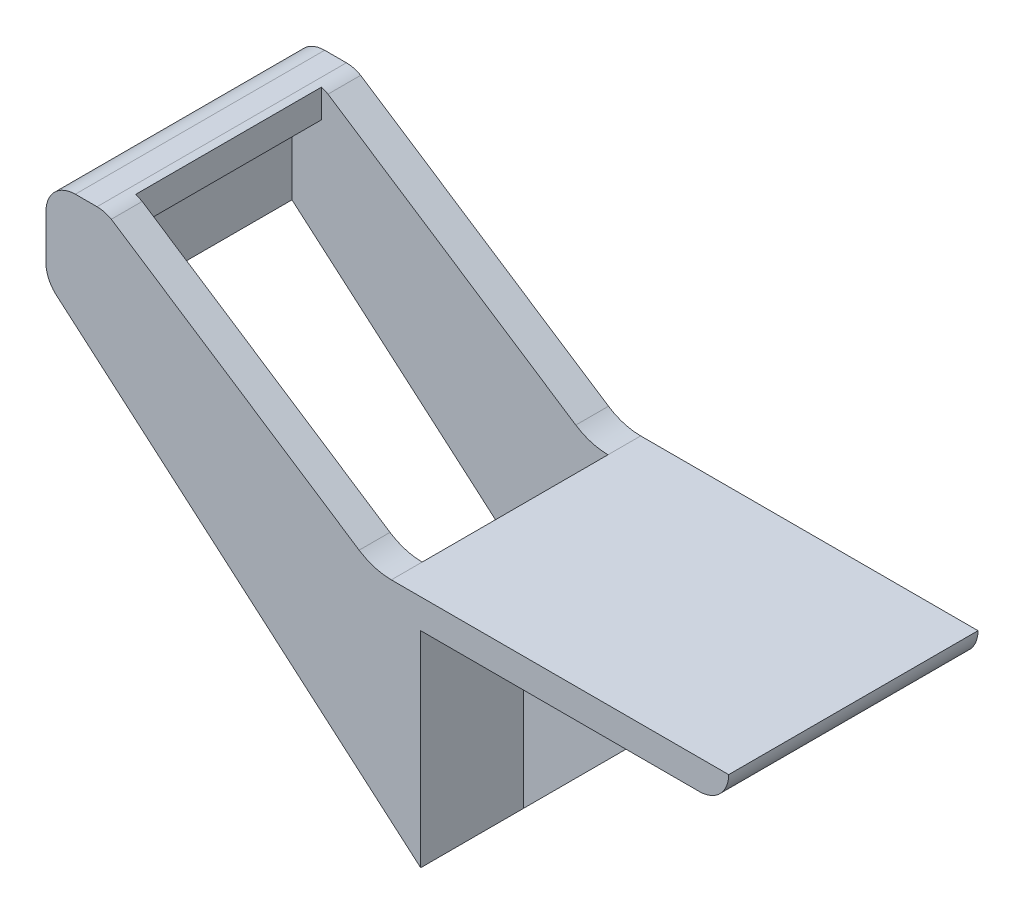
from build123d import *

# Parameters (mm, degrees)
BOSS_EXTRUDE2_DEPTH     = 26.9875
SKETCH3_W               = 62.061672923
SKETCH3_H               = 40.225982375
CUT_EXTRUDE1_DEPTH      = 39.1
CUT_EXTRUDE1_DEPTH_BACK = 51.8
SKETCH4_W               = 6.35
SKETCH4_H               = 40.225982375
CUT_EXTRUDE2_DEPTH      = 31.75
BOSS_EXTRUDE3_DEPTH     = 4.7625


with BuildPart() as part:
    # Sketch1 → Boss-Extrude2 (new body, symmetric)
    with BuildSketch(Plane.XY):
        with BuildLine():
            Line((66.675, 0), (-6.35, 0))
            ThreePointArc((-6.35, 0), (-9.986642245, 0.531810604), (-13.318716788, 2.082703436))
            Line((-13.318716788, 2.082703436), (-66.971034996, 37.297676322))
            ThreePointArc((-66.971034996, 37.297676322), (-68.46461012, 37.896146949), (-70.06066077, 38.1))
            Line((-70.06066077, 38.1), (-74.761672923, 38.1))
            ThreePointArc((-74.761672923, 38.1), (-79.251800983, 36.240128061), (-81.111672923, 31.75))
            Line((-81.111672923, 31.75), (-81.111672923, 21.961704715))
            ThreePointArc((-81.111672923, 21.961704715), (-80.533790997, 19.314979768), (-78.90532554, 17.149985376))
            Line((-78.90532554, 17.149985376), (0, -50.8))
            Line((0, -50.8), (0, -6.35))
            Line((0, -6.35), (60.325, -6.35))
            ThreePointArc((60.325, -6.35), (64.815128061, -4.490128061), (66.675, 0))
        make_face()
    extrude(amount=BOSS_EXTRUDE2_DEPTH, both=True)

    # Sketch3 → Cut-Extrude1 (cut, two sides)
    with BuildSketch(Plane(origin=(0, 0, 0), x_dir=(1, 0, 0), z_dir=(0, 1, 0))) as cut_extrude1_sk:
        with Locations((-37.380836461, -0.195905759)):
            Rectangle(SKETCH3_W, SKETCH3_H)
    extrude(amount=CUT_EXTRUDE1_DEPTH, mode=Mode.SUBTRACT)
    extrude(cut_extrude1_sk.sketch, amount=-CUT_EXTRUDE1_DEPTH_BACK, mode=Mode.SUBTRACT)

    # Sketch4 → Cut-Extrude2 (cut)
    with BuildSketch(Plane(origin=(0, 0, 0), x_dir=(1, 0, 0), z_dir=(0, 1, 0))):
        with Locations((-71.586672923, -0.195905759)):
            Rectangle(SKETCH4_W, SKETCH4_H)
    extrude(amount=CUT_EXTRUDE2_DEPTH, mode=Mode.SUBTRACT)

    # Sketch5 → Boss-Extrude3 (add, symmetric)
    with BuildSketch(Plane.XY):
        Polygon((0, -50.8), (44.45, -6.35), (0, -6.35), align=None)
    extrude(amount=BOSS_EXTRUDE3_DEPTH, both=True)


solid = part.part
